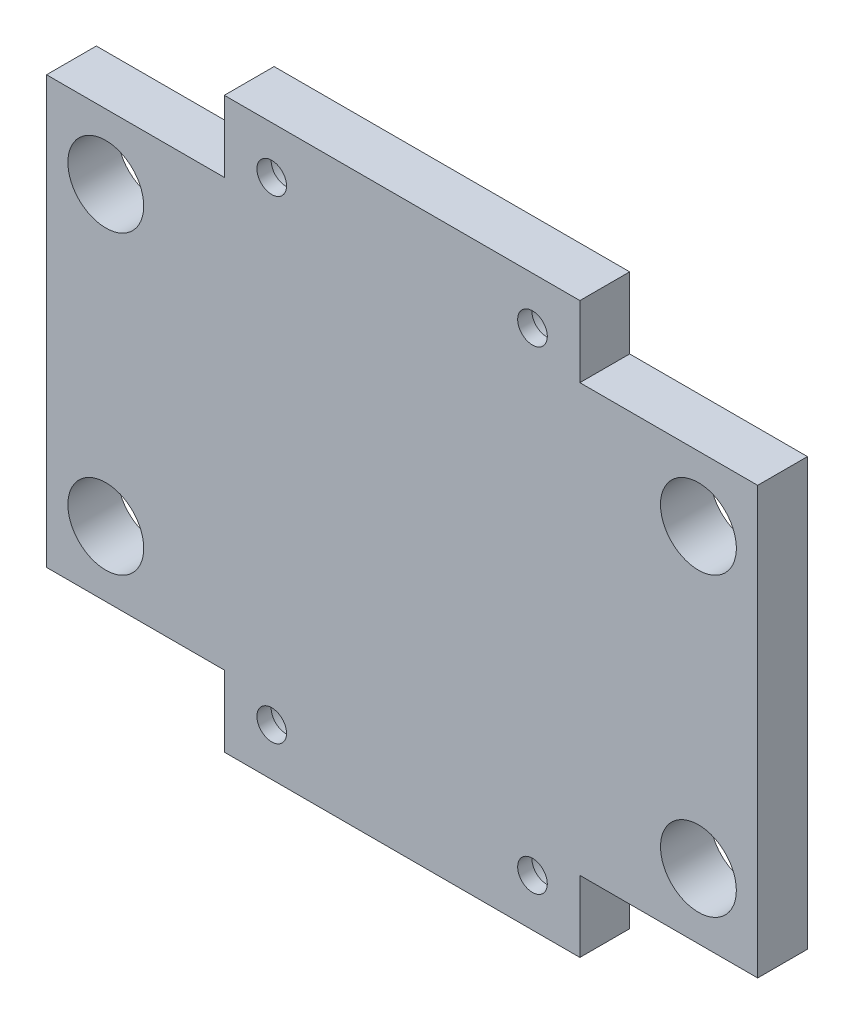
from build123d import *

# Parameters (mm, degrees)
SKETCH_1_R          = 3.2
SKETCH_1_R_2        = 1.25
EXTRUDE_1_DEPTH     = 4.2
SKETCH_2_R          = 2.5
CUT_EXTRUDE_1_DEPTH = 3


with BuildPart() as part:
    # 스케치1 → 보스-돌출1 (new body)
    with BuildSketch(Plane.XY):
        Polygon((15, 24), (-15, 24), (-15, 18), (-30, 18), (-30, -18), (-15, -18), (-15, -24), (15, -24), (15, -18), (30, -18), (30, 18), (15, 18), align=None)
        with Locations((-25, 12.5)):
            Circle(SKETCH_1_R, mode=Mode.SUBTRACT)
        with Locations((-11, 20)):
            Circle(SKETCH_1_R_2, mode=Mode.SUBTRACT)
        with Locations((-11, -20)):
            Circle(SKETCH_1_R_2, mode=Mode.SUBTRACT)
        with Locations((-25, -12.5)):
            Circle(SKETCH_1_R, mode=Mode.SUBTRACT)
        with Locations((25, -12.5)):
            Circle(SKETCH_1_R, mode=Mode.SUBTRACT)
        with Locations((11, -20)):
            Circle(SKETCH_1_R_2, mode=Mode.SUBTRACT)
        with Locations((11, 20)):
            Circle(SKETCH_1_R_2, mode=Mode.SUBTRACT)
        with Locations((25, 12.5)):
            Circle(SKETCH_1_R, mode=Mode.SUBTRACT)
    extrude(amount=EXTRUDE_1_DEPTH)

    # 스케치2 → 컷-돌출1 (cut)
    with BuildSketch(Plane(origin=(0, 0, 0), x_dir=(-1, 0, 0), z_dir=(0, 0, -1))):
        with Locations((-11, 20)):
            Circle(SKETCH_2_R)
        with Locations((11, 20)):
            Circle(SKETCH_2_R)
        with Locations((11, -20)):
            Circle(SKETCH_2_R)
        with Locations((-11, -20)):
            Circle(SKETCH_2_R)
    extrude(amount=-CUT_EXTRUDE_1_DEPTH, mode=Mode.SUBTRACT)


solid = part.part
